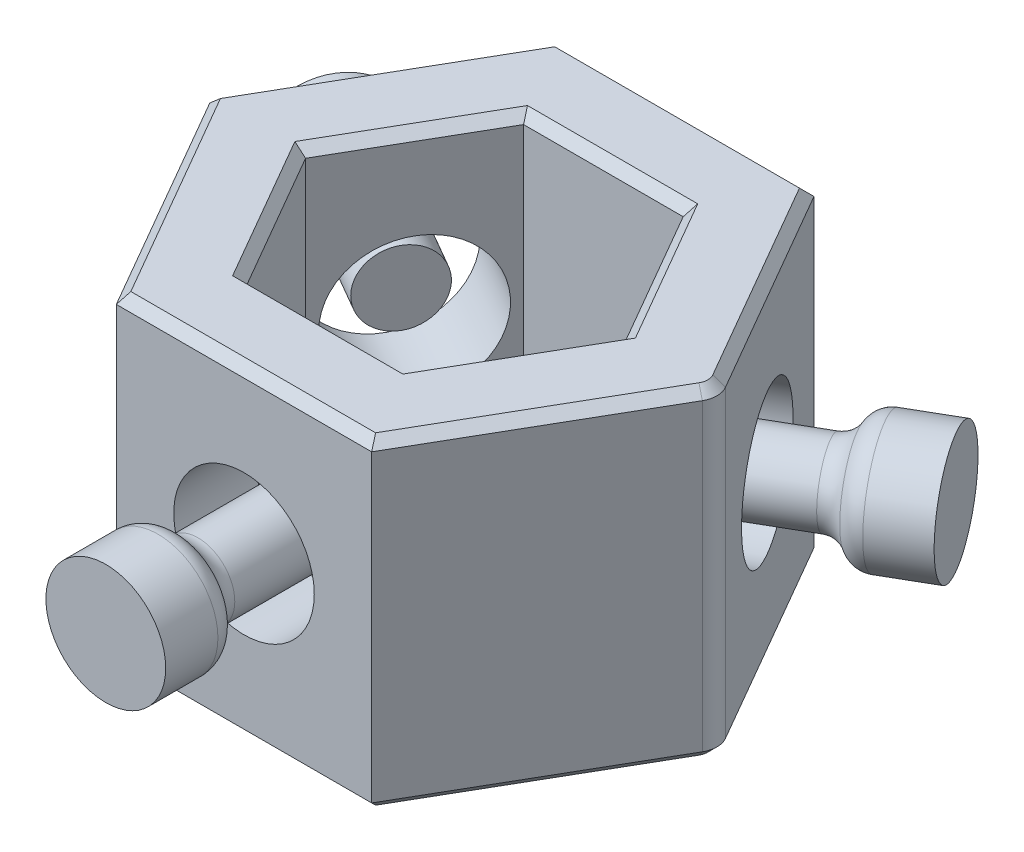
from build123d import *

# Parameters (mm, degrees)
SALIENTE_EXTRUIR1_DEPTH             = 14
CORTAR_EXTRUIR1_DEPTH               = 15
DI_METRO_DE_TALADRO_6_1_6_1_1_D     = 6.1
DI_METRO_DE_TALADRO_6_1_6_1_1_DEPTH = 3.6
DI_METRO_DE_TALADRO_6_1_6_1_2_D     = 6.1
DI_METRO_DE_TALADRO_6_1_6_1_2_DEPTH = 3.6
DI_METRO_DE_TALADRO_6_1_6_1_3_D     = 6.1
DI_METRO_DE_TALADRO_6_1_6_1_3_DEPTH = 3.6
REDONDEO2_R                         = 1
CHAFL_N1_SIZE                       = 0.4


with BuildPart() as part:
    # Croquis1 → Saliente-Extruir1 (new body)
    with BuildSketch(Plane.XZ.offset(14)):
        Polygon((-5.542562584, -9.6), (5.542562584, -9.6), (11.085125168, 0), (5.542562584, 9.6), (-5.542562584, 9.6), (-11.085125168, 0), align=None)
    extrude(amount=-SALIENTE_EXTRUIR1_DEPTH)

    # Croquis2 → Cortar-Extruir1 (cut, through all)
    with BuildSketch(Plane(origin=(0, 0, 0), x_dir=(-1, 0, 0), z_dir=(0, 1, 0))):
        Polygon((6.92820323, 0), (3.464101615, 6), (-3.464101615, 6), (-6.92820323, 0), (-3.464101615, -6), (3.464101615, -6), align=None)
    extrude(amount=-CORTAR_EXTRUIR1_DEPTH, mode=Mode.SUBTRACT)

    # Diámetro de taladro Ø6.1 (6.1)1
    with Locations(Plane.XY.offset(9.6)):
        with Locations((0, -7)):
            Hole(DI_METRO_DE_TALADRO_6_1_6_1_1_D / 2, depth=DI_METRO_DE_TALADRO_6_1_6_1_1_DEPTH)

    # Diámetro de taladro Ø6.1 (6.1)2
    with Locations(Plane(origin=(-8.313843876, 0, -4.8), x_dir=(-0.5, 0, 0.866025404), z_dir=(-0.866025404, 0, -0.5))):
        with Locations((0, -7)):
            Hole(DI_METRO_DE_TALADRO_6_1_6_1_2_D / 2, depth=DI_METRO_DE_TALADRO_6_1_6_1_2_DEPTH)

    # Diámetro de taladro Ø6.1 (6.1)3
    with Locations(Plane(origin=(8.313843876, 0, -4.8), x_dir=(-0.5, 0, -0.866025404), z_dir=(0.866025404, 0, -0.5))):
        with Locations((0, -7)):
            Hole(DI_METRO_DE_TALADRO_6_1_6_1_3_D / 2, depth=DI_METRO_DE_TALADRO_6_1_6_1_3_DEPTH)

    # Redondeo2
    redondeo2_edges = [part.edges().sort_by_distance(p)[0] for p in [
        (11.085125168, -7, 0),
    ]]
    fillet(redondeo2_edges, radius=REDONDEO2_R)

    # Chaflán1
    chafl_n1_edges = [part.edges().sort_by_distance(p)[0] for p in [
        (8.169506309, 0, -5.05),
        (0, 0, 9.6),
        (-8.313843876, 0, 4.8),
        (-5.196152423, -14, -3),
        (0, -14, -6),
        (5.196152423, -14, -3),
        (5.196152423, -14, 3),
        (0, -14, 6),
        (-5.196152423, -14, 3),
        (-5.196152423, 0, -3),
        (-5.196152423, 0, 3),
        (0, 0, 6),
        (5.196152423, 0, 3),
        (5.196152423, 0, -3),
        (0, 0, -6),
        (-8.313843876, 0, -4.8),
        (8.169506309, -14, 5.05),
        (10.93042463, -14, 0),
        (8.169506309, 0, 5.05),
        (10.93042463, 0, 0),
        (-8.313843876, -14, 4.8),
        (0, -14, 9.6),
        (8.169506309, -14, -5.05),
        (0, -14, -9.6),
        (-8.313843876, -14, -4.8),
        (0, 0, -9.6),
    ]]
    chamfer(chafl_n1_edges, length=CHAFL_N1_SIZE)


with BuildPart() as body_2:
    # Croquis9 → Revolución1 (revolve)
    with BuildSketch(Plane(origin=(0, -7, 0), x_dir=(1, 0, 0), z_dir=(0, 1, 0))):
        with BuildLine():
            Line((1.6, -7.6), (0, -7.6))
            Line((0, -7.6), (0, -15.6))
            Line((0, -15.6), (2.6, -15.6))
            Line((2.6, -15.6), (2.6, -13.332050808))
            ThreePointArc((2.6, -13.332050808), (2.466025404, -12.832050808), (2.1, -12.466025404))
            ThreePointArc((2.1, -12.466025404), (1.733974596, -12.1), (1.6, -11.6))
            Line((1.6, -11.6), (1.6, -7.6))
        make_face()
    revolve(axis=Axis((0, -7, 7.6), (0, 0, 1)))


with BuildPart() as body_3:
    # Croquis10 → Revolución2 (revolve)
    with BuildSketch(Plane.XZ.offset(7)):
        with BuildLine():
            Line((-5.781793069, -5.185640646), (-6.581793069, -3.8))
            Line((-6.581793069, -3.8), (-13.509996299, -7.8))
            Line((-13.509996299, -7.8), (-12.209996299, -10.05166605))
            Line((-12.209996299, -10.05166605), (-10.245894684, -8.917691454))
            ThreePointArc((-10.245894684, -8.917691454), (-9.87986928, -8.55166605), (-9.745894684, -8.05166605))
            ThreePointArc((-9.745894684, -8.05166605), (-9.611920088, -7.55166605), (-9.245894684, -7.185640646))
            Line((-9.245894684, -7.185640646), (-5.781793069, -5.185640646))
        make_face()
    revolve(axis=Axis((-5.981793069, -7, -3.453589838), (-0.866025404, 0, -0.5)))


with BuildPart() as body_4:
    # Croquis11 → Revolución3 (revolve)
    with BuildSketch(Plane.XZ.offset(7)):
        with BuildLine():
            Line((7.381793069, -2.414359354), (6.581793069, -3.8))
            Line((6.581793069, -3.8), (13.509996299, -7.8))
            Line((13.509996299, -7.8), (14.809996299, -5.54833395))
            Line((14.809996299, -5.54833395), (12.845894684, -4.414359354))
            ThreePointArc((12.845894684, -4.414359354), (12.345894684, -4.280384758), (11.845894684, -4.414359354))
            ThreePointArc((11.845894684, -4.414359354), (11.345894684, -4.54833395), (10.845894684, -4.414359354))
            Line((10.845894684, -4.414359354), (7.381793069, -2.414359354))
        make_face()
    revolve(axis=Axis((8.313843876, -7, -4.8), (0.866025404, 0, -0.5)))


solid = Compound([part.part, body_2.part, body_3.part, body_4.part])
